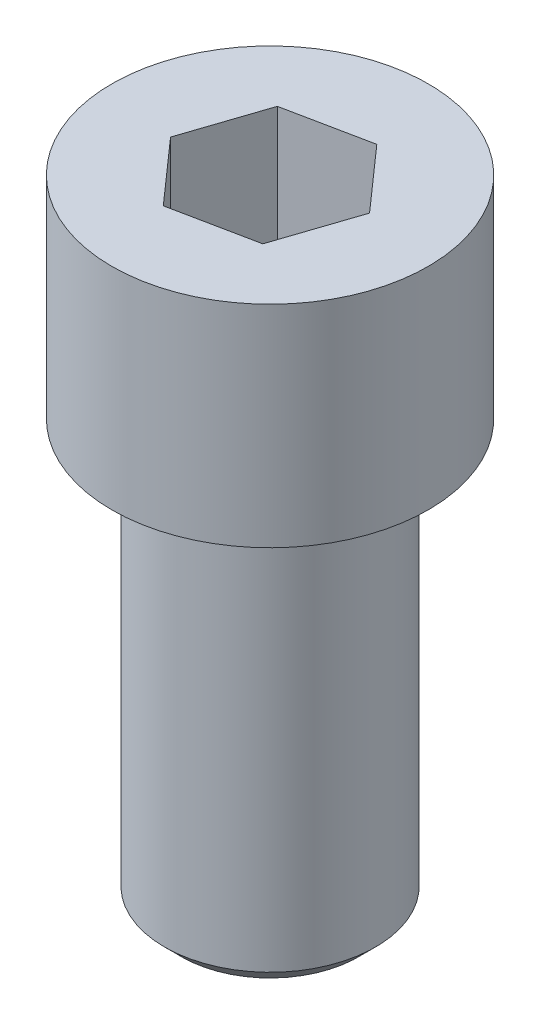
from build123d import *

# Parameters (mm, degrees)
SKETCH1_R           = 1.875
BOSS_EXTRUDE1_DEPTH = 2.5
SKETCH2_R           = 1.25
BOSS_EXTRUDE2_DEPTH = 5
FILLET1_R           = 0.15
CHAMFER1_SIZE       = 0.2
CUT_EXTRUDE1_DEPTH  = 1.5


with BuildPart() as part:
    # Sketch1 → Boss-Extrude1 (new body)
    with BuildSketch(Plane(origin=(0, 0, 0), x_dir=(1, 0, 0), z_dir=(0, 1, 0))):
        Circle(SKETCH1_R)
    extrude(amount=BOSS_EXTRUDE1_DEPTH)

    # Sketch2 → Boss-Extrude2 (add)
    with BuildSketch(Plane(origin=(0, 0, 0), x_dir=(-1, 0, 0), z_dir=(0, -1, 0))):
        Circle(SKETCH2_R)
    extrude(amount=BOSS_EXTRUDE2_DEPTH)

    # Fillet1
    fillet1_edges = [part.edges().sort_by_distance(p)[0] for p in [
        (1.25, 0, 0),
    ]]
    fillet(fillet1_edges, radius=FILLET1_R)

    # Chamfer1
    chamfer1_edges = [part.edges().sort_by_distance(p)[0] for p in [
        (1.25, -5, 0),
    ]]
    chamfer(chamfer1_edges, length=CHAMFER1_SIZE)

    # Sketch3 → Cut-Extrude1 (cut)
    with BuildSketch(Plane(origin=(0, 2.5, 0), x_dir=(1, 0, 0), z_dir=(0, 1, 0))):
        Polygon((-0.979908124, -0.199449414), (-0.317225803, -0.948350036), (0.662682321, -0.748900622), (0.979908124, 0.199449414), (0.317225803, 0.948350036), (-0.662682321, 0.748900622), align=None)
    extrude(amount=-CUT_EXTRUDE1_DEPTH, mode=Mode.SUBTRACT)


solid = part.part
